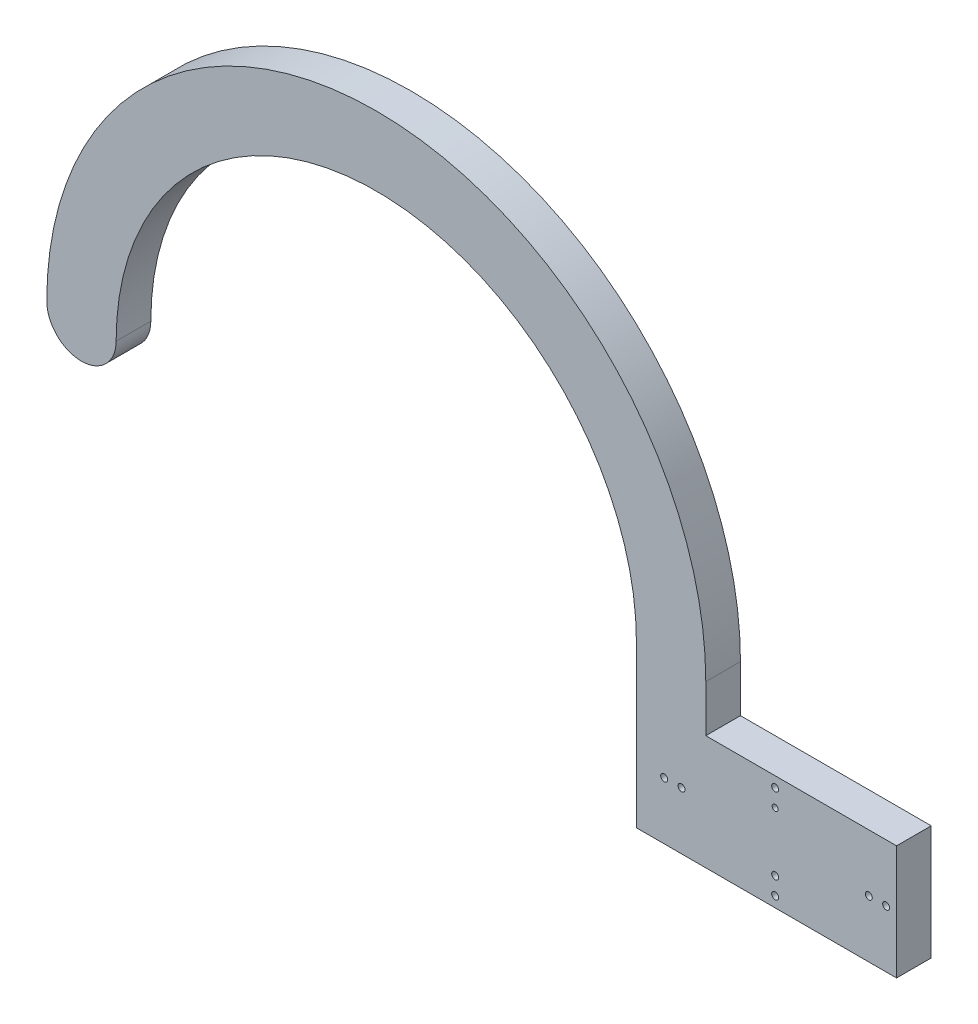
from build123d import *

# Parameters (mm, degrees)
SKETCH1_R           = 0.5
SKETCH1_R_2         = 0.429709329
BOSS_EXTRUDE1_DEPTH = 5


with BuildPart() as part:
    # Sketch1 → Boss-Extrude1 (new body)
    with BuildSketch(Plane.XY):
        with BuildLine():
            Line((85, 0), (85, -6.75))
            Line((85, -6.75), (112.500186095, -6.75))
            Line((112.500186095, -6.75), (112.500186095, -23.25))
            Line((112.500186095, -23.25), (77.499813905, -23.25))
            Line((77.499813905, -23.25), (75, -23.25))
            Line((75, -23.25), (75, 0))
            ThreePointArc((75, 0), (37.5, 37.5), (0, 0))
            ThreePointArc((0, 0), (-5, -5), (-10, 0))
            ThreePointArc((-10, 0), (37.5, 47.5), (85, 0))
        make_face()
        with Locations((95, -8.25)):
            Circle(SKETCH1_R, mode=Mode.SUBTRACT)
        with Locations((95, -10.75)):
            Circle(SKETCH1_R_2, mode=Mode.SUBTRACT)
        with Locations((95, -21.73)):
            Circle(SKETCH1_R, mode=Mode.SUBTRACT)
        with Locations((95, -19.23)):
            Circle(SKETCH1_R, mode=Mode.SUBTRACT)
        with Locations((111.000186095, -15)):
            Circle(SKETCH1_R, mode=Mode.SUBTRACT)
        with Locations((108.500186095, -15)):
            Circle(SKETCH1_R, mode=Mode.SUBTRACT)
        with Locations((81.500186095, -15)):
            Circle(SKETCH1_R, mode=Mode.SUBTRACT)
        with Locations((79.000186095, -15)):
            Circle(SKETCH1_R, mode=Mode.SUBTRACT)
    extrude(amount=BOSS_EXTRUDE1_DEPTH)


solid = part.part
